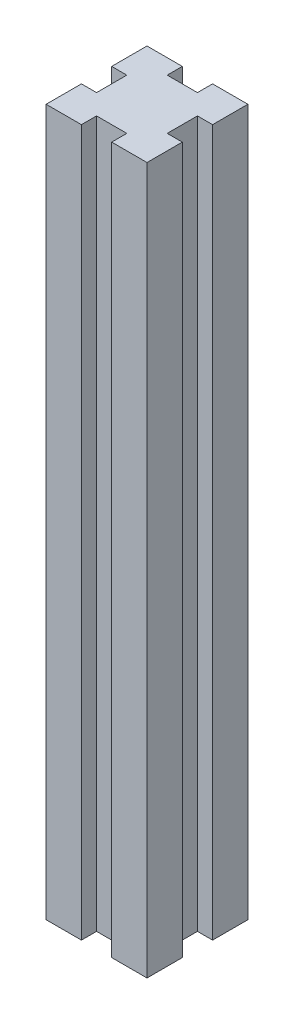
from build123d import *

# Parameters (mm, degrees)
EXTRUDE_1_DEPTH = 140


with BuildPart() as part:
    # 스케치1 → 보스-돌출1 (new body)
    with BuildSketch(Plane(origin=(0, 0, 0), x_dir=(1, 0, 0), z_dir=(0, 1, 0))):
        Polygon((3, 10), (10, 10), (10, 3), (7, 3), (7, -3), (10, -3), (10, -10), (3, -10), (3, -7), (-3, -7), (-3, -10), (-10, -10), (-10, -3), (-7, -3), (-7, 3), (-10, 3), (-10, 10), (-3, 10), (-3, 7), (3, 7), align=None)
    extrude(amount=EXTRUDE_1_DEPTH)


solid = part.part
